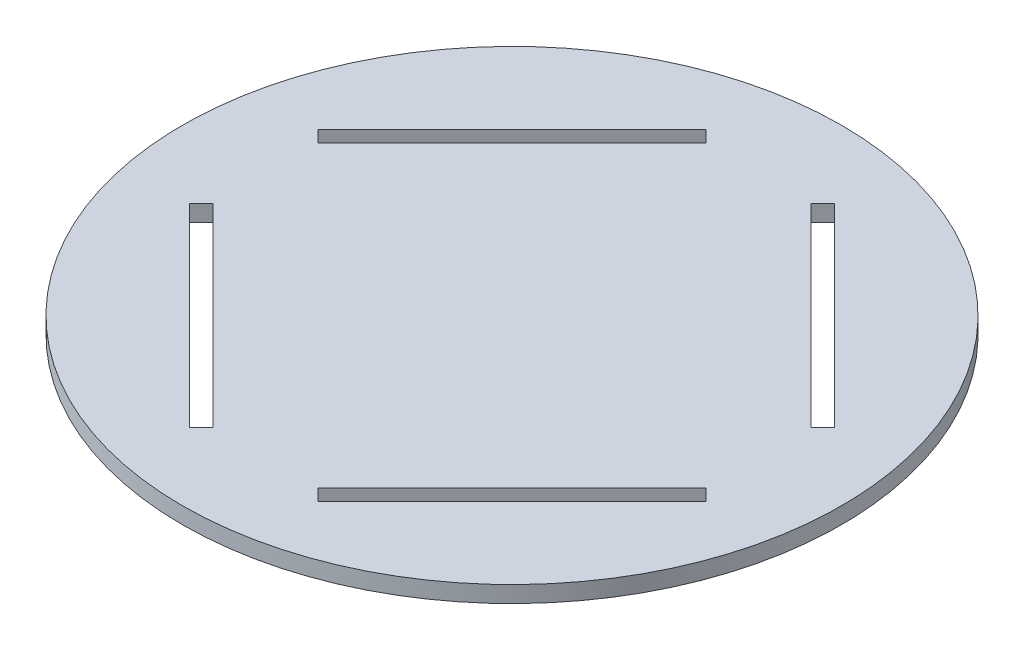
from build123d import *

# Parameters (mm, degrees)
SKETCH1_R           = 60
BOSS_EXTRUDE1_DEPTH = 1.5
CUT_EXTRUDE3_START  = -4
CUT_EXTRUDE3_DEPTH  = 5
CIRPATTERN1_COUNT   = 4


with BuildPart() as part:
    # Sketch1 → Boss-Extrude1 (new body, symmetric)
    with BuildSketch(Plane(origin=(0, 0, 0), x_dir=(1, 0, 0), z_dir=(0, 1, 0))):
        Circle(SKETCH1_R)
    extrude(amount=BOSS_EXTRUDE1_DEPTH, both=True)

    # Sketch4 → Cut-Extrude3 (cut)
    with BuildSketch(Plane(origin=(0, 1.5, 0), x_dir=(1, 0, 0), z_dir=(0, 1, 0)).offset(CUT_EXTRUDE3_START)):
        Polygon((9.545941546, 44.901280605), (44.901280605, 9.545941546), (47.022600949, 11.66726189), (11.66726189, 47.022600949), align=None)
    cut_extrude3 = extrude(amount=CUT_EXTRUDE3_DEPTH, mode=Mode.SUBTRACT)

    # CirPattern1: Cut-Extrude3 ×4 about axis
    cirpattern1_axis = Axis((0, 0, 0), (0, 1, 0))
    for i in range(1, CIRPATTERN1_COUNT):
        add(cut_extrude3.rotate(cirpattern1_axis, i * 360 / CIRPATTERN1_COUNT), mode=Mode.SUBTRACT)


solid = part.part
